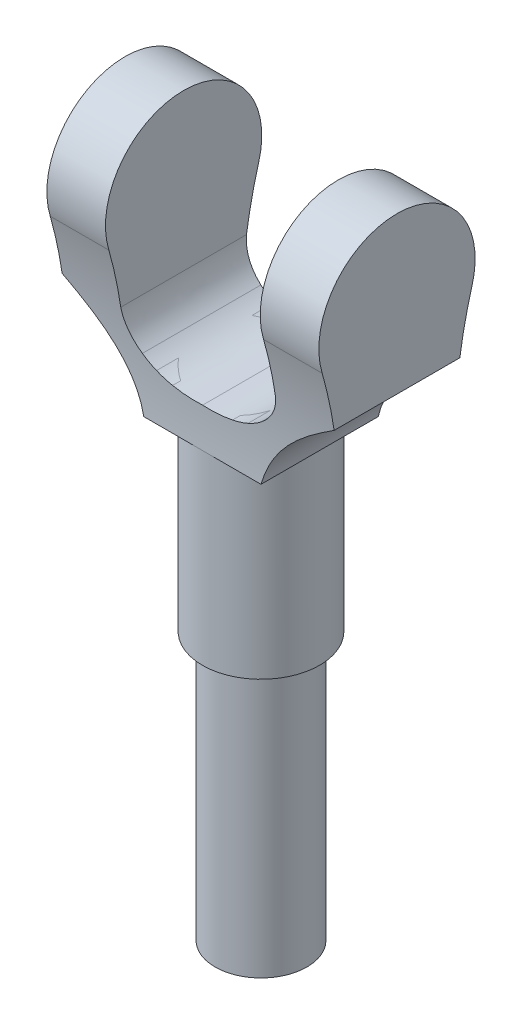
from build123d import *

# Parameters (mm, degrees)
SKETCH1_R                = 11.75
BOSS_EXTRUDE1_DEPTH      = 68.5
SKETCH2_R                = 15
BOSS_EXTRUDE2_DEPTH      = 90
BOSS_EXTRUDE8_DEPTH      = 20
BOSS_EXTRUDE8_DEPTH_BACK = 20
CUT_EXTRUDE1_DEPTH       = 183.957071595
CUT_EXTRUDE1_DEPTH_BACK  = 183.957071595
CUT_EXTRUDE3_DEPTH       = 183.957071595
CUT_EXTRUDE3_DEPTH_BACK  = 183.957071595


with BuildPart() as part:
    # Sketch1 → Boss-Extrude1 (new body)
    with BuildSketch(Plane(origin=(0, 0, 0), x_dir=(1, 0, 0), z_dir=(0, 1, 0))):
        Circle(SKETCH1_R)
    extrude(amount=BOSS_EXTRUDE1_DEPTH)

    # Sketch2 → Boss-Extrude2 (add)
    with BuildSketch(Plane(origin=(0, 68.5, 0), x_dir=(1, 0, 0), z_dir=(0, 1, 0))):
        Circle(SKETCH2_R)
    extrude(amount=BOSS_EXTRUDE2_DEPTH)

    # Sketch3 → Boss-Extrude8 (add, two sides: drawn at the far end of the back side and taken through both)
    with BuildSketch(Plane.XY.offset(-BOSS_EXTRUDE8_DEPTH_BACK)):
        with BuildLine():
            Line((34.8, 178.5), (19.8, 178.5))
            Line((19.8, 178.5), (19.8, 138.5))
            add(Edge.make_bspline(
                [(19.8, 138.5), (19.342041835, 130.113579731), (9.499038784, 125.49619678), (2.081328753, 126.395752952)],
                knots=[0, 0, 0, 0, 1, 1, 1, 1], degree=3))
            Line((2.081328753, 126.395752952), (-2.081328753, 126.395752952))
            add(Edge.make_bspline(
                [(-19.8, 138.5), (-19.342041835, 130.113579731), (-9.499038784, 125.49619678), (-2.081328753, 126.395752952)],
                knots=[0, 0, 0, 0, 1, 1, 1, 1], degree=3))
            Line((-19.8, 138.5), (-19.8, 178.5))
            Line((-19.8, 178.5), (-34.8, 178.5))
            Line((-34.8, 178.5), (-34.8, 138.5))
            add(Edge.make_bspline(
                [(-34.8, 138.5), (-26.593752286, 132.956992939), (-17.534962697, 126.326659818), (-15, 116.109720846)],
                knots=[0, 0, 0, 0, 1, 1, 1, 1], degree=3))
            Line((-15, 116.109720846), (15, 116.109720846))
            add(Edge.make_bspline(
                [(34.8, 138.5), (26.593752286, 132.956992939), (17.534962697, 126.326659818), (15, 116.109720846)],
                knots=[0, 0, 0, 0, 1, 1, 1, 1], degree=3))
            Line((34.8, 138.5), (34.8, 178.5))
        make_face()
    extrude(amount=BOSS_EXTRUDE8_DEPTH + BOSS_EXTRUDE8_DEPTH_BACK)

    # Sketch4 → Cut-Extrude1 (cut, two sides: drawn at the far end of the back side and taken through both)
    with BuildSketch(Plane(origin=(0, 0, 0), x_dir=(0, 0, -1), z_dir=(1, 0, 0)).offset(-CUT_EXTRUDE1_DEPTH_BACK)):
        with BuildLine():
            Line((-20, 158.5), (-20, 116.109720846))
            Line((-20, 116.109720846), (-15, 116.109720846))
            add(Edge.make_bspline(
                [(-19.133651392, 152.677338717), (-14.085853038, 134.832908572), (-15, 116.109720846)],
                knots=[0.017804831, 0.017804831, 0.017804831, 1, 1, 1], degree=2))
            ThreePointArc((-19.133651392, 152.677338717), (-19.782227223, 155.556619956), (-20, 158.5))
        make_face()
        with BuildLine():
            Line((-20, 178.5), (-20, 158.5))
            ThreePointArc((-20, 158.5), (-14.142135543, 172.642135704), (2.27e-07, 178.5))
            Line((2.27e-07, 178.5), (-20, 178.5))
        make_face()
        with BuildLine():
            Line((20, 178.5), (2.27e-07, 178.5))
            ThreePointArc((2.27e-07, 178.5), (14.142135704, 172.642135543), (20, 158.5))
            Line((20, 158.5), (20, 178.5))
        make_face()
        with BuildLine():
            ThreePointArc((20, 158.5), (19.782227223, 155.556619956), (19.133651392, 152.677338717))
            add(Edge.make_bspline(
                [(19.133651392, 152.677338717), (14.085853038, 134.832908572), (15, 116.109720846)],
                knots=[0.017804831, 0.017804831, 0.017804831, 1, 1, 1], degree=2))
            Line((15, 116.109720846), (20, 116.109720846))
            Line((20, 116.109720846), (20, 158.5))
        make_face()
    extrude(amount=CUT_EXTRUDE1_DEPTH + CUT_EXTRUDE1_DEPTH_BACK, mode=Mode.SUBTRACT)

    # Sketch5 → Cut-Extrude3 (cut, two sides: drawn at the far end of the back side and taken through both)
    with BuildSketch(Plane.XY.offset(-CUT_EXTRUDE3_DEPTH_BACK)):
        with BuildLine():
            Line((-15, 158.5), (-15.195230311, 130.107554831))
            add(Edge.make_bspline(
                [(-15.195230311, 130.107554831), (-10.965318452, 126.739214623), (-5.254865436, 125.838577277), (0, 126.128155298)],
                knots=[0, 0, 0, 0, 1, 1, 1, 1], degree=3))
            add(Edge.make_bspline(
                [(15.195230311, 130.107554831), (10.965318452, 126.739214623), (5.254865436, 125.838577277), (0, 126.128155298)],
                knots=[0, 0, 0, 0, 1, 1, 1, 1], degree=3))
            Line((15.195230311, 130.107554831), (15, 158.5))
            Line((15, 158.5), (-15, 158.5))
        make_face()
    extrude(amount=CUT_EXTRUDE3_DEPTH + CUT_EXTRUDE3_DEPTH_BACK, mode=Mode.SUBTRACT)


solid = part.part
